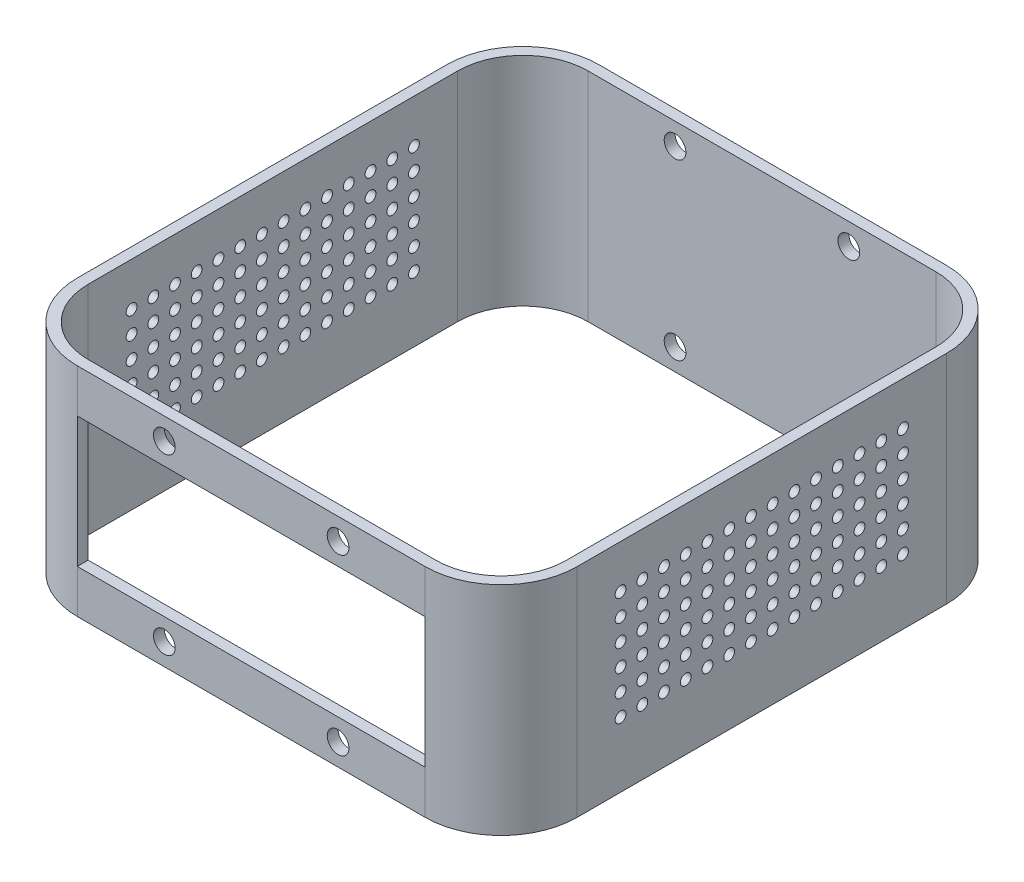
from build123d import *

# Parameters (mm, degrees)
BOSS_EXTRUDE1_DEPTH = 100
SKETCH12_R          = 5
CUT_EXTRUDE2_DEPTH  = 10
SKETCH13_R          = 5
CUT_EXTRUDE3_DEPTH  = 10
SKETCH16_W          = 160.15
SKETCH16_H          = 60
CUT_EXTRUDE4_DEPTH  = 10
SKETCH17_R          = 2.5
CUT_EXTRUDE6_DEPTH  = 231.15


with BuildPart() as part:
    # Sketch1 → Boss-Extrude1 (new body)
    with BuildSketch(Plane(origin=(0, 0, 0), x_dir=(1, 0, 0), z_dir=(0, 1, 0))):
        with BuildLine():
            Line((-5, 30), (-5, 200.15))
            ThreePointArc((-5, 200.15), (5.251262658, 224.898737342), (30, 235.15))
            Line((30, 235.15), (190.15, 235.15))
            ThreePointArc((190.15, 235.15), (214.898737342, 224.898737342), (225.15, 200.15))
            Line((225.15, 200.15), (225.15, 30))
            ThreePointArc((225.15, 30), (214.898737342, 5.251262658), (190.15, -5))
            Line((190.15, -5), (30, -5))
            ThreePointArc((30, -5), (5.251262658, 5.251262658), (-5, 30))
        make_face()
        with BuildLine():
            Line((30, 0), (190.15, 0))
            ThreePointArc((190.15, 0), (211.363203436, 8.786796564), (220.15, 30))
            Line((220.15, 30), (220.15, 200.15))
            ThreePointArc((220.15, 200.15), (211.363203436, 221.363203436), (190.15, 230.15))
            Line((190.15, 230.15), (30, 230.15))
            ThreePointArc((30, 230.15), (8.786796564, 221.363203436), (0, 200.15))
            Line((0, 200.15), (0, 30))
            ThreePointArc((0, 30), (8.786796564, 8.786796564), (30, 0))
        make_face(mode=Mode.SUBTRACT)
    extrude(amount=BOSS_EXTRUDE1_DEPTH)

    # Sketch12 → Cut-Extrude2 (cut)
    with BuildSketch(Plane(origin=(0, 0, -235.15), x_dir=(-1, 0, 0), z_dir=(0, 0, -1))):
        with Locations((-150.075, 90)):
            Circle(SKETCH12_R)
        with Locations((-70.075, 90)):
            Circle(SKETCH12_R)
        with Locations((-70.075, 10)):
            Circle(SKETCH12_R)
        with Locations((-150.075, 10)):
            Circle(SKETCH12_R)
    extrude(amount=-CUT_EXTRUDE2_DEPTH, mode=Mode.SUBTRACT)

    # Sketch13 → Cut-Extrude3 (cut)
    with BuildSketch(Plane.XY.offset(5)):
        with Locations((70.075, 90)):
            Circle(SKETCH13_R)
        with Locations((150.075, 90)):
            Circle(SKETCH13_R)
        with Locations((150.075, 10)):
            Circle(SKETCH13_R)
        with Locations((70.075, 10)):
            Circle(SKETCH13_R)
    extrude(amount=-CUT_EXTRUDE3_DEPTH, mode=Mode.SUBTRACT)

    # Sketch16 → Cut-Extrude4 (cut)
    with BuildSketch(Plane.XY.offset(5)):
        with Locations((110.075, 50)):
            Rectangle(SKETCH16_W, SKETCH16_H)
    extrude(amount=-CUT_EXTRUDE4_DEPTH, mode=Mode.SUBTRACT)

    # Sketch17 → Cut-Extrude6 (cut, through all)
    with BuildSketch(Plane(origin=(225.15, 0, 0), x_dir=(0, 0, -1), z_dir=(1, 0, 0))):
        with Locations((50, 80)):
            Circle(SKETCH17_R)
        with Locations((60, 80)):
            Circle(SKETCH17_R)
        with Locations((70, 80)):
            Circle(SKETCH17_R)
        with Locations((80, 80)):
            Circle(SKETCH17_R)
        with Locations((90, 80)):
            Circle(SKETCH17_R)
        with Locations((100, 80)):
            Circle(SKETCH17_R)
        with Locations((110, 80)):
            Circle(SKETCH17_R)
        with Locations((120, 80)):
            Circle(SKETCH17_R)
        with Locations((130, 80)):
            Circle(SKETCH17_R)
        with Locations((140, 80)):
            Circle(SKETCH17_R)
        with Locations((150, 80)):
            Circle(SKETCH17_R)
        with Locations((160, 80)):
            Circle(SKETCH17_R)
        with Locations((170, 80)):
            Circle(SKETCH17_R)
        with Locations((180, 80)):
            Circle(SKETCH17_R)
        with Locations((60, 70)):
            Circle(SKETCH17_R)
        with Locations((70, 70)):
            Circle(SKETCH17_R)
        with Locations((80, 70)):
            Circle(SKETCH17_R)
        with Locations((90, 70)):
            Circle(SKETCH17_R)
        with Locations((100, 70)):
            Circle(SKETCH17_R)
        with Locations((110, 70)):
            Circle(SKETCH17_R)
        with Locations((120, 70)):
            Circle(SKETCH17_R)
        with Locations((130, 70)):
            Circle(SKETCH17_R)
        with Locations((140, 70)):
            Circle(SKETCH17_R)
        with Locations((150, 70)):
            Circle(SKETCH17_R)
        with Locations((160, 70)):
            Circle(SKETCH17_R)
        with Locations((170, 70)):
            Circle(SKETCH17_R)
        with Locations((180, 70)):
            Circle(SKETCH17_R)
        with Locations((60, 60)):
            Circle(SKETCH17_R)
        with Locations((70, 60)):
            Circle(SKETCH17_R)
        with Locations((80, 60)):
            Circle(SKETCH17_R)
        with Locations((90, 60)):
            Circle(SKETCH17_R)
        with Locations((100, 60)):
            Circle(SKETCH17_R)
        with Locations((110, 60)):
            Circle(SKETCH17_R)
        with Locations((120, 60)):
            Circle(SKETCH17_R)
        with Locations((130, 60)):
            Circle(SKETCH17_R)
        with Locations((140, 60)):
            Circle(SKETCH17_R)
        with Locations((150, 60)):
            Circle(SKETCH17_R)
        with Locations((160, 60)):
            Circle(SKETCH17_R)
        with Locations((170, 60)):
            Circle(SKETCH17_R)
        with Locations((180, 60)):
            Circle(SKETCH17_R)
        with Locations((60, 50)):
            Circle(SKETCH17_R)
        with Locations((70, 50)):
            Circle(SKETCH17_R)
        with Locations((80, 50)):
            Circle(SKETCH17_R)
        with Locations((90, 50)):
            Circle(SKETCH17_R)
        with Locations((100, 50)):
            Circle(SKETCH17_R)
        with Locations((110, 50)):
            Circle(SKETCH17_R)
        with Locations((120, 50)):
            Circle(SKETCH17_R)
        with Locations((130, 50)):
            Circle(SKETCH17_R)
        with Locations((140, 50)):
            Circle(SKETCH17_R)
        with Locations((150, 50)):
            Circle(SKETCH17_R)
        with Locations((160, 50)):
            Circle(SKETCH17_R)
        with Locations((170, 50)):
            Circle(SKETCH17_R)
        with Locations((180, 50)):
            Circle(SKETCH17_R)
        with Locations((60, 40)):
            Circle(SKETCH17_R)
        with Locations((70, 40)):
            Circle(SKETCH17_R)
        with Locations((80, 40)):
            Circle(SKETCH17_R)
        with Locations((90, 40)):
            Circle(SKETCH17_R)
        with Locations((100, 40)):
            Circle(SKETCH17_R)
        with Locations((110, 40)):
            Circle(SKETCH17_R)
        with Locations((120, 40)):
            Circle(SKETCH17_R)
        with Locations((130, 40)):
            Circle(SKETCH17_R)
        with Locations((140, 40)):
            Circle(SKETCH17_R)
        with Locations((150, 40)):
            Circle(SKETCH17_R)
        with Locations((160, 40)):
            Circle(SKETCH17_R)
        with Locations((170, 40)):
            Circle(SKETCH17_R)
        with Locations((180, 40)):
            Circle(SKETCH17_R)
        with Locations((60, 30)):
            Circle(SKETCH17_R)
        with Locations((70, 30)):
            Circle(SKETCH17_R)
        with Locations((80, 30)):
            Circle(SKETCH17_R)
        with Locations((90, 30)):
            Circle(SKETCH17_R)
        with Locations((100, 30)):
            Circle(SKETCH17_R)
        with Locations((110, 30)):
            Circle(SKETCH17_R)
        with Locations((120, 30)):
            Circle(SKETCH17_R)
        with Locations((130, 30)):
            Circle(SKETCH17_R)
        with Locations((140, 30)):
            Circle(SKETCH17_R)
        with Locations((150, 30)):
            Circle(SKETCH17_R)
        with Locations((160, 30)):
            Circle(SKETCH17_R)
        with Locations((170, 30)):
            Circle(SKETCH17_R)
        with Locations((180, 30)):
            Circle(SKETCH17_R)
        with Locations((50, 70)):
            Circle(SKETCH17_R)
        with Locations((50, 60)):
            Circle(SKETCH17_R)
        with Locations((50, 50)):
            Circle(SKETCH17_R)
        with Locations((50, 40)):
            Circle(SKETCH17_R)
        with Locations((50, 30)):
            Circle(SKETCH17_R)
    extrude(amount=-CUT_EXTRUDE6_DEPTH, mode=Mode.SUBTRACT)


solid = part.part
